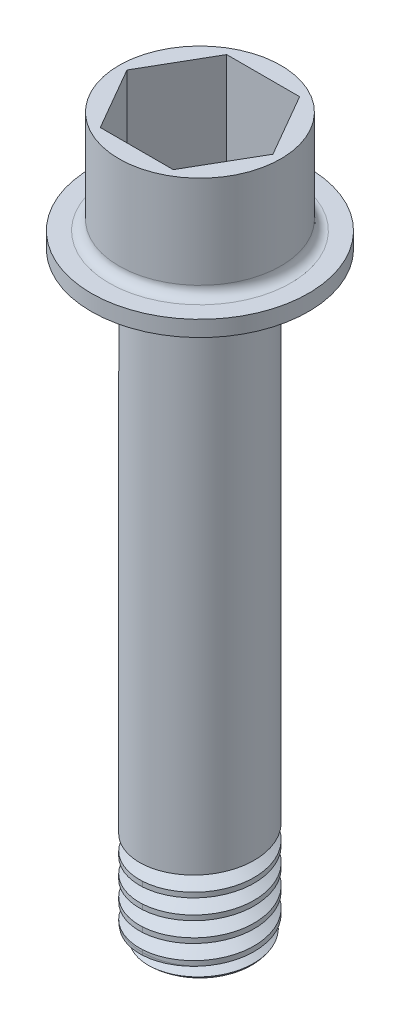
from build123d import *

# Parameters (mm, degrees)
ESBO_O1_R                       = 5.82
RESSALTO_EXTRUS_O1_DEPTH        = 60.8
ESBO_O2_R                       = 11
RESSALTO_EXTRUS_O2_DEPTH        = 12
FILETE1_R                       = 2
CORTE_EXTRUS_O1_DEPTH           = 10.4
ESBO_O4_R                       = 3.7
CORTE_EXTRUS_O2_DEPTH           = 61
ESBO_O5_R                       = 2
CORTE_EXTRUS_O3_DEPTH           = 2
FILETE2_R                       = 2
VARREDURA_DE_CORTE1_PITCH       = 2
VARREDURA_DE_CORTE1_HEIGHT      = 10.4
VARREDURA_DE_CORTE1_RADIUS      = 5.82
VARREDURA_DE_CORTE1_START_ANGLE = -180
ESBO_O10_OUTSIDE_W              = 39.834
ESBO_O10_OUTSIDE_H              = 39.834
ESBO_O10_OUTSIDE_R              = 8.2
CORTE_EXTRUS_O4_DEPTH           = 10.4
FILETE3_R                       = 1
CORTE_EXTRUS_O6_DEPTH           = 10


with BuildPart() as part:
    # Esboço1 → Ressalto-extrusão1 (new body)
    with BuildSketch(Plane(origin=(0, 0, 0), x_dir=(1, 0, 0), z_dir=(0, 1, 0))):
        Circle(ESBO_O1_R)
    extrude(amount=RESSALTO_EXTRUS_O1_DEPTH)

    # Esboço2 → Ressalto-extrusão2 (add)
    with BuildSketch(Plane(origin=(0, 60.8, 0), x_dir=(1, 0, 0), z_dir=(0, 1, 0))):
        Circle(ESBO_O2_R)
    extrude(amount=RESSALTO_EXTRUS_O2_DEPTH)

    # Filete1
    filete1_edges = [part.edges().sort_by_distance(p)[0] for p in [
        (-5.82, 60.8, 0),
    ]]
    fillet(filete1_edges, radius=FILETE1_R)

    # Esboço3 → Corte-extrusão1 (cut)
    with BuildSketch(Plane(origin=(0, 72.8, 0), x_dir=(1, 0, 0), z_dir=(0, 1, 0))):
        Polygon((-7.390083446, 0), (-3.695041723, -6.4), (3.695041723, -6.4), (7.390083446, 0), (3.695041723, 6.4), (-3.695041723, 6.4), align=None)
    extrude(amount=-CORTE_EXTRUS_O1_DEPTH, mode=Mode.SUBTRACT)

    # Esboço4 → Corte-extrusão2 (cut)
    with BuildSketch(Plane.XZ):
        Circle(ESBO_O4_R)
    extrude(amount=-CORTE_EXTRUS_O2_DEPTH, mode=Mode.SUBTRACT)

    # Esboço5 → Corte-extrusão3 (cut)
    with BuildSketch(Plane(origin=(0, 62.4, 0), x_dir=(1, 0, 0), z_dir=(0, 1, 0))):
        Circle(ESBO_O5_R)
    extrude(amount=-CORTE_EXTRUS_O3_DEPTH, mode=Mode.SUBTRACT)

    # Filete2
    filete2_edges = [part.edges().sort_by_distance(p)[0] for p in [
        (-5.82, 0, 0),
    ]]
    fillet(filete2_edges, radius=FILETE2_R)

    # Varredura de corte1: sweep along a helix
    with BuildLine() as varredura_de_corte1_path:
        add(Helix(VARREDURA_DE_CORTE1_PITCH, VARREDURA_DE_CORTE1_HEIGHT, VARREDURA_DE_CORTE1_RADIUS, center=(0, 0, 0), direction=(0, 1, 0), mode=Mode.PRIVATE).rotate(Axis((0, 0, 0), (0, 1, 0)), VARREDURA_DE_CORTE1_START_ANGLE))
    # Esboço9 → Varredura de corte1 (sweep, cut)
    with BuildSketch(Plane(origin=(0, 0, 0), x_dir=(0, 0, -1), z_dir=(1, 0, 0))):
        Polygon((4.5198, 0), (6.4698, -1.125833025), (6.4698, 1.125833025), align=None)
    sweep(path=varredura_de_corte1_path.line, is_frenet=True, mode=Mode.SUBTRACT)

    # Esboço10 outside → Corte-extrusão4 (cut)
    with BuildSketch(Plane(origin=(0, 72.8, 0), x_dir=(1, 0, 0), z_dir=(0, 1, 0))):
        Rectangle(ESBO_O10_OUTSIDE_W, ESBO_O10_OUTSIDE_H)
        Circle(ESBO_O10_OUTSIDE_R, mode=Mode.SUBTRACT)
    extrude(amount=-CORTE_EXTRUS_O4_DEPTH, mode=Mode.SUBTRACT)

    # Filete3
    filete3_edges = [part.edges().sort_by_distance(p)[0] for p in [
        (-8.2, 62.4, 0),
    ]]
    fillet(filete3_edges, radius=FILETE3_R)

    # Esboço12 → Corte-extrusão6 (cut)
    with BuildSketch(Plane(origin=(0, 0, 0), x_dir=(-0.951056516, 0, -0.309016994), z_dir=(0.309016994, 0, -0.951056516))):
        Polygon((5.82, 9.64932918), (5.82, 11.15067082), (4.5198, 10.4), align=None)
    extrude(amount=-CORTE_EXTRUS_O6_DEPTH, mode=Mode.SUBTRACT)


solid = part.part
